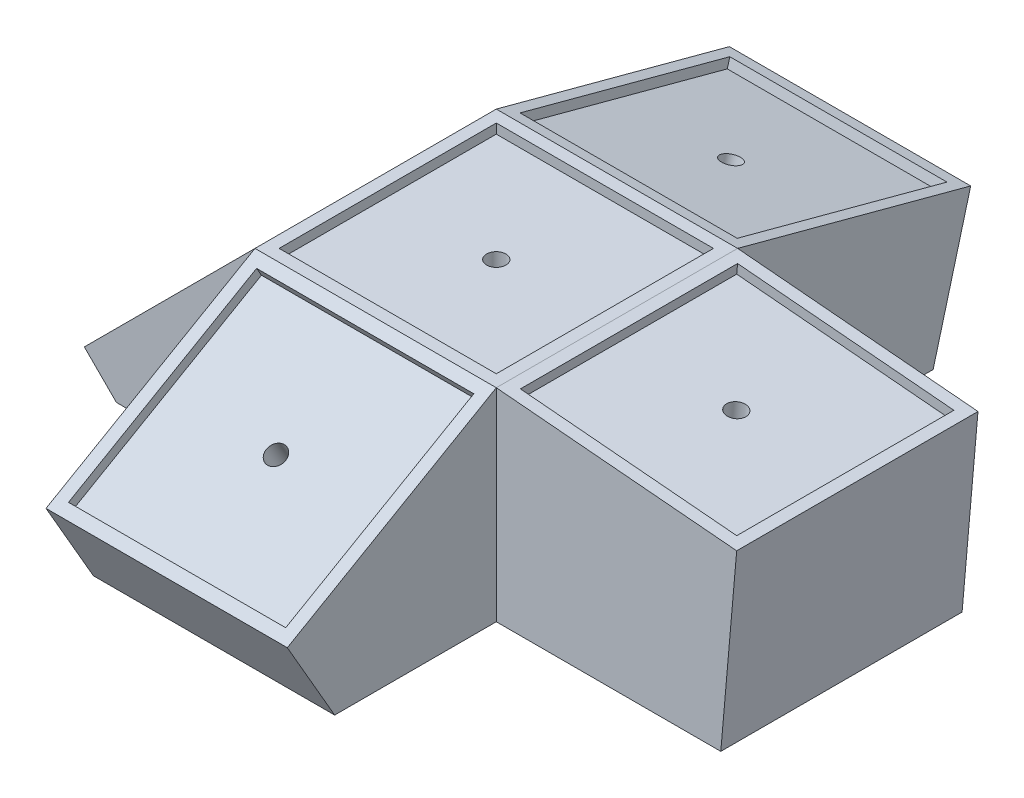
from build123d import *

# Parameters (mm, degrees)
SKETCH1_W            = 63.5
SKETCH1_H            = 63.5
SKETCH1_W_2          = 57.15
SKETCH1_H_2          = 57.15
BOSS_EXTRUDE1_DEPTH  = 2.54
SKETCH2_W            = 63.5
SKETCH2_H            = 63.5
BOSS_EXTRUDE2_DEPTH  = 8.89
SKETCH3_R            = 2.54
CUT_EXTRUDE1_DEPTH   = 8.89
SKETCH4_W            = 63.5
SKETCH4_H            = 63.5
SKETCH4_W_2          = 57.15
SKETCH4_H_2          = 57.15
BOSS_EXTRUDE3_DEPTH  = 2.54
SKETCH5_W            = 63.5
SKETCH5_H            = 63.5
BOSS_EXTRUDE4_DEPTH  = 8.89
SKETCH6_R            = 2.54
CUT_EXTRUDE2_DEPTH   = 8.89
SKETCH7_W            = 63.5
SKETCH7_H            = 63.5
SKETCH7_W_2          = 57.15
SKETCH7_H_2          = 57.15
BOSS_EXTRUDE5_DEPTH  = 2.54
SKETCH8_W            = 63.5
SKETCH8_H            = 63.5
BOSS_EXTRUDE6_DEPTH  = 8.89
SKETCH9_R            = 2.54
CUT_EXTRUDE3_DEPTH   = 8.89
SKETCH10_W           = 63.5
SKETCH10_H           = 63.5
SKETCH10_W_2         = 57.15
SKETCH10_H_2         = 57.15
BOSS_EXTRUDE7_DEPTH  = 2.54
SKETCH11_W           = 63.5
SKETCH11_H           = 63.5
BOSS_EXTRUDE8_DEPTH  = 8.89
SKETCH12_R           = 2.54
CUT_EXTRUDE4_DEPTH   = 8.89
SKETCH14_W           = 63.5
SKETCH14_H           = 63.5
SKETCH14_W_2         = 57.15
SKETCH14_H_2         = 57.15
BOSS_EXTRUDE10_DEPTH = 2.54
SKETCH15_W           = 63.5
SKETCH15_H           = 63.5
BOSS_EXTRUDE11_DEPTH = 8.89
SKETCH16_R           = 2.54
CUT_EXTRUDE5_DEPTH   = 8.89
BOSS_EXTRUDE12_REACH = 55.34
SKETCH18_W           = 63.258363329
SKETCH18_H           = 63.5
CUT_EXTRUDE7_REACH   = 53.155
SKETCH19_W           = 21.300485008
SKETCH19_H           = 63.5
BOSS_EXTRUDE15_REACH = 55.34
SKETCH20_W           = 63.5
SKETCH20_H           = 58.16761314
CUT_EXTRUDE8_START   = -13.499985
SKETCH21_W           = 63.5
SKETCH21_H           = 36.305948049
CUT_EXTRUDE8_DEPTH   = 13.499985
BOSS_EXTRUDE16_REACH = 55.34
SKETCH22_W           = 48.076280605
SKETCH22_H           = 63.5
CUT_EXTRUDE9_START   = -0.504151
SKETCH23_W           = 63.5
SKETCH23_H           = 4.915504187
CUT_EXTRUDE9_DEPTH   = 0.504151
BOSS_EXTRUDE18_REACH = 55.34
SKETCH24_W           = 63.5
SKETCH24_H           = 64.511289969
CUT_EXTRUDE10_START  = -26.776858
SKETCH25_W           = 63.5
SKETCH25_H           = 23.443872205
CUT_EXTRUDE10_DEPTH  = 26.776858
SKETCH26_W           = 63.5
SKETCH26_H           = 63.5
BOSS_EXTRUDE19_DEPTH = 41.91


with BuildPart() as part:
    # Sketch1 → Boss-Extrude1 (new body)
    with BuildSketch(Plane(origin=(0, 0, 0), x_dir=(1, 0, 0), z_dir=(0, 1, 0))):
        with Locations((28.575, 28.575)):
            Rectangle(SKETCH1_W, SKETCH1_H)
        with Locations((28.575, 28.575)):
            Rectangle(SKETCH1_W_2, SKETCH1_H_2, mode=Mode.SUBTRACT)
    extrude(amount=BOSS_EXTRUDE1_DEPTH)

    # Sketch2 → Boss-Extrude2 (add)
    with BuildSketch(Plane.XZ):
        with Locations((28.575, -28.575)):
            Rectangle(SKETCH2_W, SKETCH2_H)
    extrude(amount=BOSS_EXTRUDE2_DEPTH)

    # Sketch3 → Cut-Extrude1 (cut)
    with BuildSketch(Plane(origin=(0, 0, 0), x_dir=(1, 0, 0), z_dir=(0, 1, 0))):
        with Locations((28.575, 28.575)):
            Circle(SKETCH3_R)
    extrude(amount=-CUT_EXTRUDE1_DEPTH, mode=Mode.SUBTRACT)



with BuildPart() as body_2:
    # Sketch4 → Boss-Extrude3 (new body)
    with BuildSketch(Plane(origin=(0.678769335, 7.758369005, 0), x_dir=(0, 0, -1), z_dir=(0.087155743, 0.996194698, 0))):
        with Locations((28.575, -91.624069576)):
            Rectangle(SKETCH4_W, SKETCH4_H)
        with Locations((28.575, -91.624069576)):
            Rectangle(SKETCH4_W_2, SKETCH4_H_2, mode=Mode.SUBTRACT)
    extrude(amount=-BOSS_EXTRUDE3_DEPTH)

    # Sketch5 → Boss-Extrude4 (add)
    with BuildSketch(Plane(origin=(0.457393749, 5.228034472, 0), x_dir=(0.996194698, -0.087155743, 0), z_dir=(-0.087155743, -0.996194698, 0))):
        with Locations((91.624069576, -28.575)):
            Rectangle(SKETCH5_W, SKETCH5_H)
    extrude(amount=BOSS_EXTRUDE4_DEPTH)

    # Sketch6 → Cut-Extrude2 (cut)
    with BuildSketch(Plane(origin=(0.457393749, 5.228034472, 0), x_dir=(0.996194698, -0.087155743, 0), z_dir=(0.087155743, 0.996194698, 0))):
        with Locations((91.624069576, 28.575)):
            Circle(SKETCH6_R)
    extrude(amount=-CUT_EXTRUDE2_DEPTH, mode=Mode.SUBTRACT)


with BuildPart() as part_1:
    add(part.part)

    add(body_2.part)  # Boss-Extrude5 merges body 2
    # Sketch7 → Boss-Extrude5 (add)
    with BuildSketch(Plane(origin=(0, 17.451102263, -4.676008758), x_dir=(-1, 0, 0), z_dir=(0, 0.965925826, -0.258819045))):
        with Locations((-28.575, -89.362075096)):
            Rectangle(SKETCH7_W, SKETCH7_H)
        with Locations((-28.575, -89.362075096)):
            Rectangle(SKETCH7_W_2, SKETCH7_H_2, mode=Mode.SUBTRACT)
    extrude(amount=-BOSS_EXTRUDE5_DEPTH)

    # Sketch8 → Boss-Extrude6 (add)
    with BuildSketch(Plane(origin=(0, 14.997650664, -4.018608384), x_dir=(1, 0, 0), z_dir=(0, -0.965925826, 0.258819045))):
        with Locations((28.575, -89.362075096)):
            Rectangle(SKETCH8_W, SKETCH8_H)
    extrude(amount=BOSS_EXTRUDE6_DEPTH)

    # Sketch9 → Cut-Extrude3 (cut)
    with BuildSketch(Plane(origin=(0, 14.997650664, -4.018608384), x_dir=(1, 0, 0), z_dir=(0, 0.965925826, -0.258819045))):
        with Locations((28.575, 89.362075096)):
            Circle(SKETCH9_R)
    extrude(amount=-CUT_EXTRUDE3_DEPTH, mode=Mode.SUBTRACT)

    # Sketch10 → Boss-Extrude7 (add)
    with BuildSketch(Plane(origin=(0, 3.279815329, 1.893602263), x_dir=(1, 0, 0), z_dir=(0, 0.866025404, 0.5))):
        with Locations((28.575, -33.229630657)):
            Rectangle(SKETCH10_W, SKETCH10_H)
        with Locations((28.575, -33.229630657)):
            Rectangle(SKETCH10_W_2, SKETCH10_H_2, mode=Mode.SUBTRACT)
    extrude(amount=-BOSS_EXTRUDE7_DEPTH)

    # Sketch11 → Boss-Extrude8 (add)
    with BuildSketch(Plane(origin=(0, 1.080110803, 0.623602263), x_dir=(1, 0, 0), z_dir=(0, -0.866025404, -0.5))):
        with Locations((28.575, 33.229630657)):
            Rectangle(SKETCH11_W, SKETCH11_H)
    extrude(amount=BOSS_EXTRUDE8_DEPTH)

    # Sketch12 → Cut-Extrude4 (cut)
    with BuildSketch(Plane(origin=(0, 1.080110803, 0.623602263), x_dir=(1, 0, 0), z_dir=(0, 0.866025404, 0.5))):
        with Locations((28.575, -33.229630657)):
            Circle(SKETCH12_R)
    extrude(amount=-CUT_EXTRUDE4_DEPTH, mode=Mode.SUBTRACT)

    # Sketch14 → Boss-Extrude10 (add)
    with BuildSketch(Plane(origin=(-2.8575, 2.8575, 0), x_dir=(0, 0, 1), z_dir=(-0.707106781, 0.707106781, 0))):
        with Locations((-28.575, -32.199012806)):
            Rectangle(SKETCH14_W, SKETCH14_H)
        with Locations((-28.575, -32.199012806)):
            Rectangle(SKETCH14_W_2, SKETCH14_H_2, mode=Mode.SUBTRACT)
    extrude(amount=-BOSS_EXTRUDE10_DEPTH)

    # Sketch15 → Boss-Extrude11 (add)
    with BuildSketch(Plane(origin=(-1.061448776, 1.061448776, 0), x_dir=(0, 0, -1), z_dir=(0.707106781, -0.707106781, 0))):
        with Locations((28.575, -32.199012806)):
            Rectangle(SKETCH15_W, SKETCH15_H)
    extrude(amount=BOSS_EXTRUDE11_DEPTH)

    # Sketch16 → Cut-Extrude5 (cut)
    with BuildSketch(Plane(origin=(-1.061448776, 1.061448776, 0), x_dir=(0, 0, 1), z_dir=(-0.707106781, 0.707106781, 0))):
        with Locations((-28.575, -32.199012806)):
            Circle(SKETCH16_R)
    extrude(amount=-CUT_EXTRUDE5_DEPTH, mode=Mode.SUBTRACT)

    # Boss-Extrude12: up to this face of the body (flat: up to its plane)
    boss_extrude12_end = Plane(part_1.part.faces().sort_by_distance((60.351110962, -8.935945156, -58.051047878))[0])
    # Sketch18 → Boss-Extrude12 (add, up to the picked face)
    with BuildSketch(Plane(origin=(0, -50.8, 0), x_dir=(1, 0, 0), z_dir=(0, 1, 0)), mode=Mode.PRIVATE) as boss_extrude12_sk1:
        with Locations((91.954181664, 28.575)):
            Rectangle(SKETCH18_W, SKETCH18_H)
    boss_extrude12_tool1 = split(extrude(boss_extrude12_sk1.sketch, amount=BOSS_EXTRUDE12_REACH, mode=Mode.PRIVATE), bisect_by=boss_extrude12_end, keep=Keep.BOTH, mode=Mode.PRIVATE)
    add(boss_extrude12_tool1.solids().sort_by_distance((91.954182, -50.8, -28.575))[0])

    # Cut-Extrude7: up to this face of the body (flat: up to its plane)
    cut_extrude7_end = Plane(part_1.part.faces().sort_by_distance((91.954181664, -50.8, -28.575))[0])
    # Sketch19 → Cut-Extrude7 (cut, up to the picked face)
    with BuildSketch(Plane(origin=(-0.317420804, -3.628136394, 0), x_dir=(0.996194698, -0.087155743, 0), z_dir=(0.087155743, 0.996194698, 0)), mode=Mode.PRIVATE) as cut_extrude7_sk1:
        with Locations((134.02431208, 28.575)):
            Rectangle(SKETCH19_W, SKETCH19_H)
    cut_extrude7_tool1 = split(extrude(cut_extrude7_sk1.sketch, amount=-CUT_EXTRUDE7_REACH, mode=Mode.PRIVATE), bisect_by=cut_extrude7_end, keep=Keep.BOTH, mode=Mode.PRIVATE)
    add(cut_extrude7_tool1.solids().sort_by_distance((133.196888, -15.309125, -28.575))[0], mode=Mode.SUBTRACT)

    # Boss-Extrude15: up to this face of the body (flat: up to its plane)
    boss_extrude15_end = Plane(part_1.part.faces().sort_by_distance((-1.691883068, -11.096545593, 3.934189806))[0])
    # Sketch20 → Boss-Extrude15 (add, up to the picked face)
    with BuildSketch(Plane(origin=(0, -50.8, 0), x_dir=(1, 0, 0), z_dir=(0, 1, 0)), mode=Mode.PRIVATE) as boss_extrude15_sk1:
        with Locations((28.575, -29.08380657)):
            Rectangle(SKETCH20_W, SKETCH20_H)
    boss_extrude15_tool1 = split(extrude(boss_extrude15_sk1.sketch, amount=BOSS_EXTRUDE15_REACH, mode=Mode.PRIVATE), bisect_by=boss_extrude15_end, keep=Keep.BOTH, mode=Mode.PRIVATE)
    add(boss_extrude15_tool1.solids().sort_by_distance((28.575, -50.8, 29.083807))[0])

    # Sketch21 → Cut-Extrude8 (cut)
    with BuildSketch(Plane(origin=(0, -6.618855037, -3.821397737), x_dir=(1, 0, 0), z_dir=(0, 0.866025404, 0.5)).offset(CUT_EXTRUDE8_START)):
        with Locations((28.575, -83.132604681)):
            Rectangle(SKETCH21_W, SKETCH21_H)
    extrude(amount=CUT_EXTRUDE8_DEPTH, mode=Mode.SUBTRACT)

    # Boss-Extrude16: up to this face of the body (flat: up to its plane)
    boss_extrude16_end = Plane(part_1.part.faces().sort_by_distance((-3.786785852, -14.23624687, 1.5875))[0])
    # Sketch22 → Boss-Extrude16 (add, up to the picked face)
    with BuildSketch(Plane(origin=(0, -50.8, 0), x_dir=(1, 0, 0), z_dir=(0, 1, 0)), mode=Mode.PRIVATE) as boss_extrude16_sk1:
        with Locations((-24.038140303, 28.575)):
            Rectangle(SKETCH22_W, SKETCH22_H)
    boss_extrude16_tool1 = split(extrude(boss_extrude16_sk1.sketch, amount=BOSS_EXTRUDE16_REACH, mode=Mode.PRIVATE), bisect_by=boss_extrude16_end, keep=Keep.BOTH, mode=Mode.PRIVATE)
    add(boss_extrude16_tool1.solids().sort_by_distance((-24.03814, -50.8, -28.575))[0])

    # Sketch23 → Cut-Extrude9 (cut)
    with BuildSketch(Plane(origin=(5.224730509, -5.224730509, 0), x_dir=(0, 0, 1), z_dir=(-0.707106781, 0.707106781, 0)).offset(CUT_EXTRUDE9_START)):
        with Locations((-28.575, -66.4067649)):
            Rectangle(SKETCH23_W, SKETCH23_H)
    extrude(amount=CUT_EXTRUDE9_DEPTH, mode=Mode.SUBTRACT)

    # Boss-Extrude18: up to this face of the body (flat: up to its plane)
    boss_extrude18_end = Plane(part_1.part.faces().sort_by_distance((-1.009372862, -9.522895431, -61.182209856))[0])
    # Sketch24 → Boss-Extrude18 (add, up to the picked face)
    with BuildSketch(Plane(origin=(0, -50.8, 0), x_dir=(1, 0, 0), z_dir=(0, 1, 0)), mode=Mode.PRIVATE) as boss_extrude18_sk1:
        with Locations((28.575, 89.405644985)):
            Rectangle(SKETCH24_W, SKETCH24_H)
    boss_extrude18_tool1 = split(extrude(boss_extrude18_sk1.sketch, amount=BOSS_EXTRUDE18_REACH, mode=Mode.PRIVATE), bisect_by=boss_extrude18_end, keep=Keep.BOTH, mode=Mode.PRIVATE)
    add(boss_extrude18_tool1.solids().sort_by_distance((28.575, -50.8, -89.405645))[0])

    # Sketch25 → Cut-Extrude10 (cut)
    with BuildSketch(Plane(origin=(0, 6.410570068, -1.717707073), x_dir=(1, 0, 0), z_dir=(0, 0.965925826, -0.258819045)).offset(CUT_EXTRUDE10_START)):
        with Locations((28.575, 132.834011199)):
            Rectangle(SKETCH25_W, SKETCH25_H)
    extrude(amount=CUT_EXTRUDE10_DEPTH, mode=Mode.SUBTRACT)

    # Sketch26 → Boss-Extrude19 (add)
    with BuildSketch(Plane(origin=(0, -50.8, 0), x_dir=(1, 0, 0), z_dir=(0, 1, 0))):
        with Locations((28.575, 28.575)):
            Rectangle(SKETCH26_W, SKETCH26_H)
    extrude(amount=BOSS_EXTRUDE19_DEPTH)


solid = part_1.part
